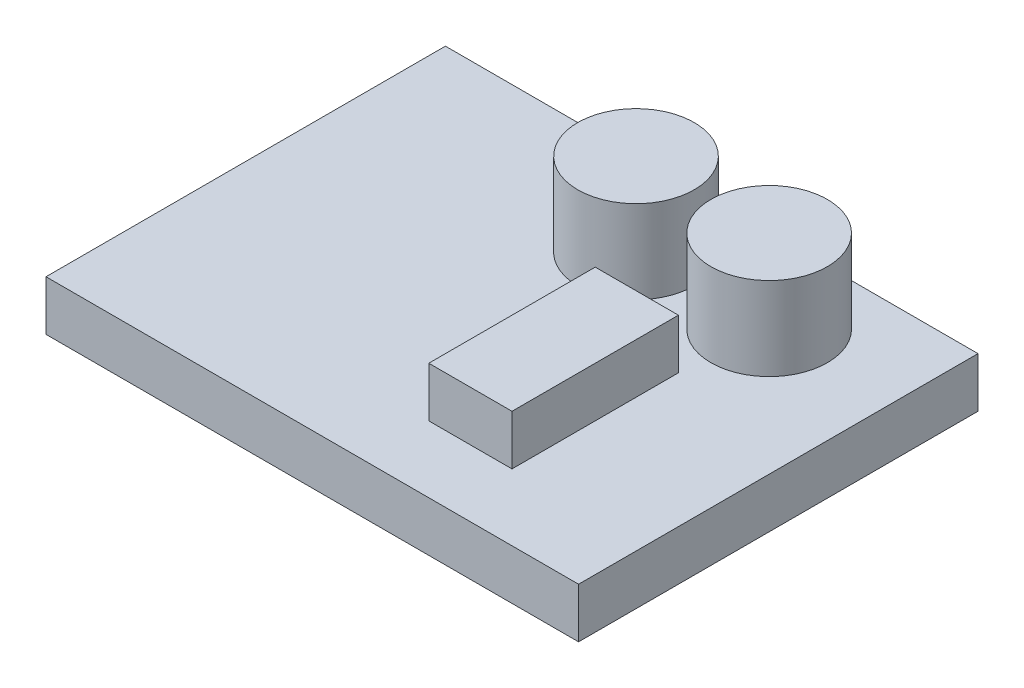
from build123d import *

# Parameters (mm, degrees)
SKETCH1_W           = 32
SKETCH1_H           = 24
BOSS_EXTRUDE1_DEPTH = 3
SKETCH2_R           = 3.5
BOSS_EXTRUDE2_DEPTH = 5
SKETCH3_W           = 5
SKETCH3_H           = 10
BOSS_EXTRUDE3_DEPTH = 3


with BuildPart() as part:
    # Sketch1 → Boss-Extrude1 (new body)
    with BuildSketch(Plane(origin=(0, 0, 0), x_dir=(1, 0, 0), z_dir=(0, 1, 0))):
        with Locations((0.62745098, -0.470588235)):
            Rectangle(SKETCH1_W, SKETCH1_H)
    extrude(amount=BOSS_EXTRUDE1_DEPTH)

    # Sketch2 → Boss-Extrude2 (add)
    with BuildSketch(Plane(origin=(0, 3, 0), x_dir=(1, 0, 0), z_dir=(0, 1, 0))):
        with Locations((1.078230838, 6.529411765)):
            Circle(SKETCH2_R)
        with Locations((9.078230838, 6.529411765)):
            Circle(SKETCH2_R)
    extrude(amount=BOSS_EXTRUDE2_DEPTH)

    # Sketch3 → Boss-Extrude3 (add)
    with BuildSketch(Plane(origin=(0, 3, 0), x_dir=(1, 0, 0), z_dir=(0, 1, 0))):
        with Locations((6.12745098, -3.470588235)):
            Rectangle(SKETCH3_W, SKETCH3_H)
    extrude(amount=BOSS_EXTRUDE3_DEPTH)


solid = part.part
